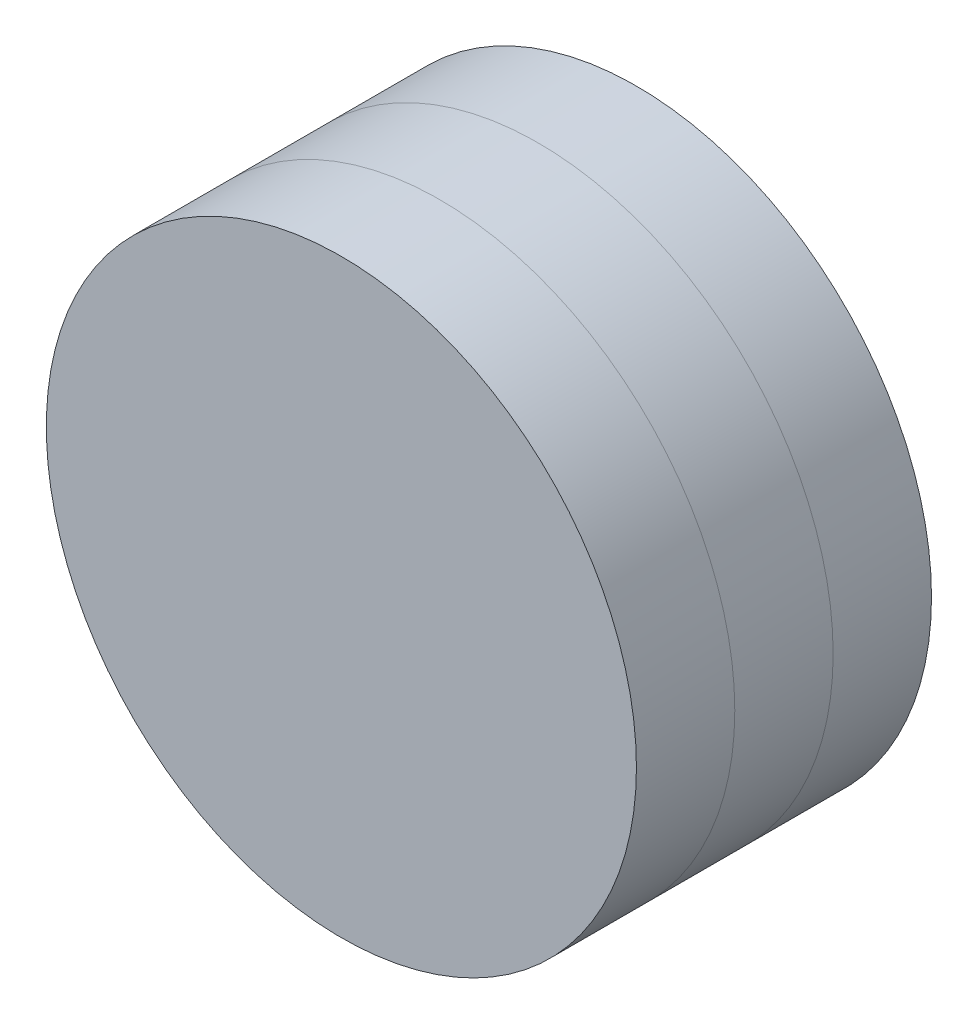
from build123d import *

# Parameters (mm, degrees)
SKETCH1_R           = 60
BOSS_EXTRUDE1_DEPTH = 20
SKETCH2_R           = 60
BOSS_EXTRUDE2_DEPTH = 20
SKETCH3_R           = 60
BOSS_EXTRUDE3_DEPTH = 20


with BuildPart() as part:
    # Sketch1 → Boss-Extrude1 (new body)
    with BuildSketch(Plane.XY):
        Circle(SKETCH1_R)
    extrude(amount=BOSS_EXTRUDE1_DEPTH)


with BuildPart() as body_2:
    # Sketch2 → Boss-Extrude2 (new body)
    with BuildSketch(Plane.XY.offset(20)):
        Circle(SKETCH2_R)
    extrude(amount=BOSS_EXTRUDE2_DEPTH)


with BuildPart() as body_3:
    # Sketch3 → Boss-Extrude3 (new body)
    with BuildSketch(Plane.XY.offset(40)):
        Circle(SKETCH3_R)
    extrude(amount=BOSS_EXTRUDE3_DEPTH)


solid = Compound([part.part, body_2.part, body_3.part])
